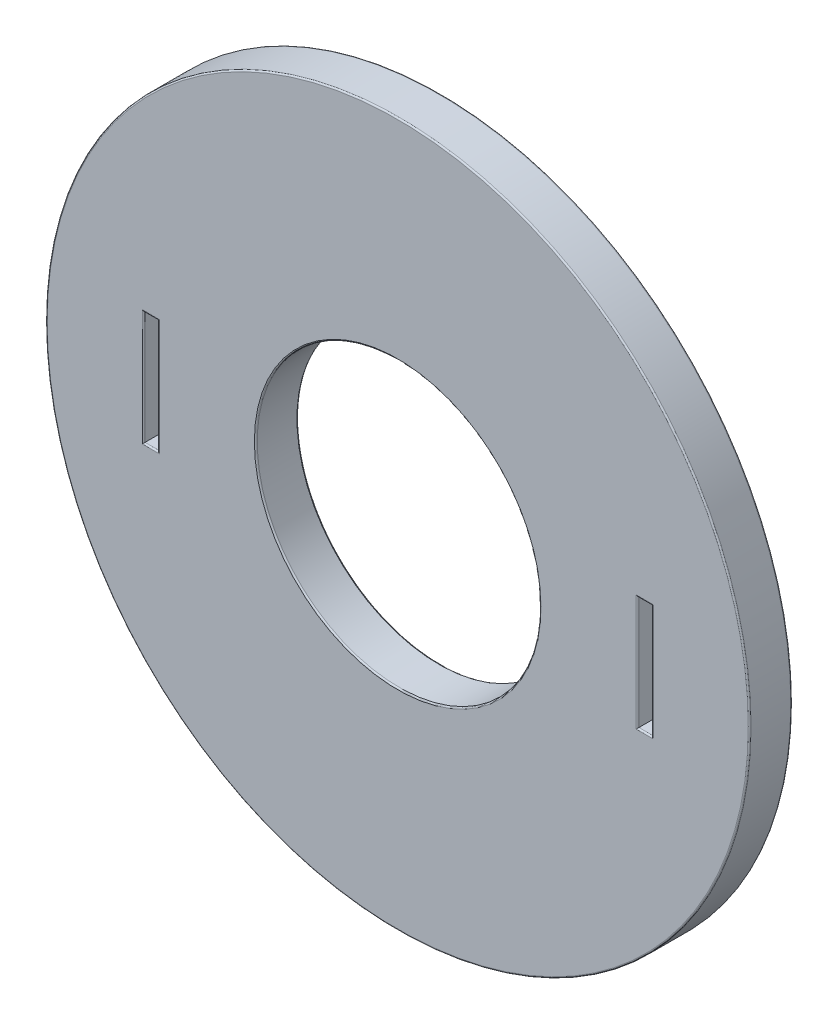
from build123d import *

# Parameters (mm, degrees)
SKETCH1_R           = 12.4
BOSS_EXTRUDE1_DEPTH = 1.5
SKETCH2_R           = 5
SKETCH2_W           = 0.5
SKETCH2_H           = 4
CUT_EXTRUDE1_DEPTH  = 2.5
FILLET1_R           = 0.05


with BuildPart() as part:
    # Sketch1 → Boss-Extrude1 (new body)
    with BuildSketch(Plane.XY):
        Circle(SKETCH1_R)
    extrude(amount=BOSS_EXTRUDE1_DEPTH)

    # Sketch2 → Cut-Extrude1 (cut, through all)
    with BuildSketch(Plane.XY.offset(1.5)):
        Circle(SKETCH2_R)
        with Locations((-8.7, 0)):
            Rectangle(SKETCH2_W, SKETCH2_H)
        with Locations((8.7, 0)):
            Rectangle(SKETCH2_W, SKETCH2_H)
    extrude(amount=-CUT_EXTRUDE1_DEPTH, mode=Mode.SUBTRACT)

    # Fillet1
    fillet1_edges = [part.edges().sort_by_distance(p)[0] for p in [
        (-8.95, 0, 0),
        (-8.7, 2, 0),
        (-8.45, 0, 0),
        (-8.7, -2, 0),
        (-8.95, 0, 1.5),
        (-8.7, -2, 1.5),
        (-8.45, 0, 1.5),
        (-8.7, 2, 1.5),
        (-12.4, 0, 0),
        (8.45, 0, 0),
        (8.7, 2, 0),
        (8.95, 0, 0),
        (8.7, -2, 0),
        (8.45, 0, 1.5),
        (8.7, -2, 1.5),
        (8.95, 0, 1.5),
        (8.7, 2, 1.5),
        (-12.4, 0, 1.5),
        (-5, 0, 0),
        (-5, 0, 1.5),
    ]]
    fillet(fillet1_edges, radius=FILLET1_R)


solid = part.part
